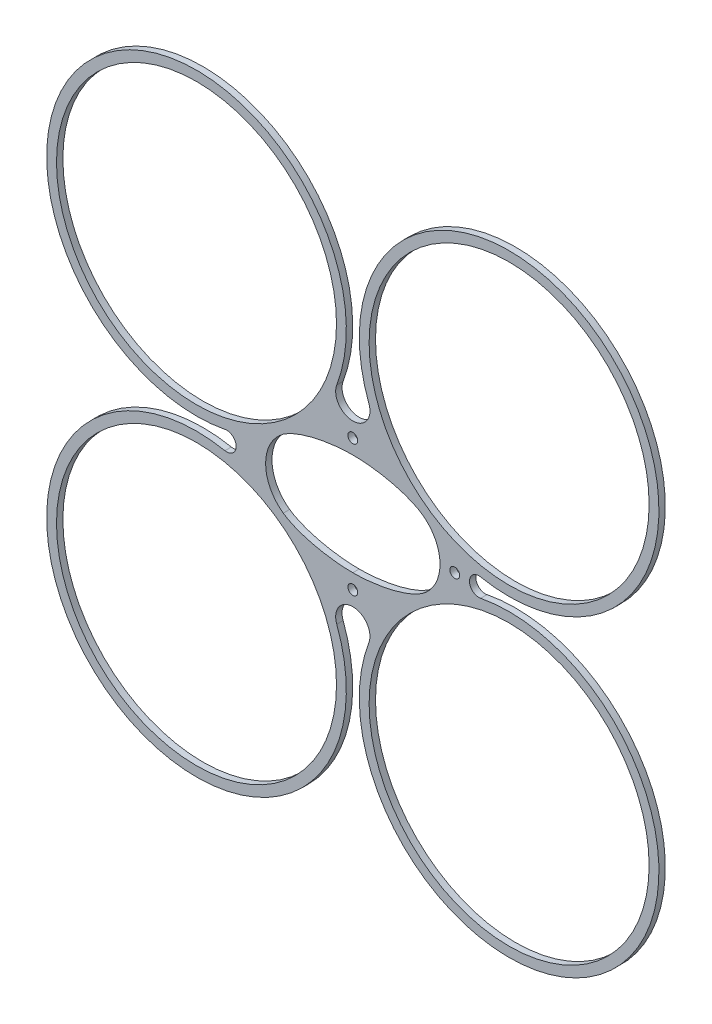
from build123d import *

# Parameters (mm, degrees)
SKETCH1_R             = 30.5
SKETCH1_R_2           = 28.5
BOSS_EXTRUDE1_DEPTH   = 1.3
BOSS_EXTRUDE1_2_DEPTH = 1.3
BOSS_EXTRUDE1_3_DEPTH = 1.3
BOSS_EXTRUDE1_4_DEPTH = 1.3
SKETCH3_R             = 1
BOSS_EXTRUDE2_DEPTH   = 1.3


with BuildPart() as part:
    # Sketch1 → Boss-Extrude1 (new body)
    with BuildSketch(Plane.XY):
        with Locations((-31.819805153, 31.819805153)):
            Circle(SKETCH1_R)
        with Locations((-31.819805153, 31.819805153)):
            Circle(SKETCH1_R_2, mode=Mode.SUBTRACT)
    extrude(amount=BOSS_EXTRUDE1_DEPTH)



with BuildPart() as body_2:
    # Sketch1 → Boss-Extrude1 2 (new body)
    with BuildSketch(Plane.XY):
        with Locations((31.819805153, 31.819805153)):
            Circle(SKETCH1_R)
        with Locations((31.819805153, 31.819805153)):
            Circle(SKETCH1_R_2, mode=Mode.SUBTRACT)
    extrude(amount=BOSS_EXTRUDE1_2_DEPTH)


with BuildPart() as body_3:
    # Sketch1 → Boss-Extrude1 3 (new body)
    with BuildSketch(Plane.XY):
        with Locations((31.819805153, -31.819805153)):
            Circle(SKETCH1_R)
        with Locations((31.819805153, -31.819805153)):
            Circle(SKETCH1_R_2, mode=Mode.SUBTRACT)
    extrude(amount=BOSS_EXTRUDE1_3_DEPTH)


with BuildPart() as body_4:
    # Sketch1 → Boss-Extrude1 4 (new body)
    with BuildSketch(Plane.XY):
        with Locations((-31.819805153, -31.819805153)):
            Circle(SKETCH1_R)
        with Locations((-31.819805153, -31.819805153)):
            Circle(SKETCH1_R_2, mode=Mode.SUBTRACT)
    extrude(amount=BOSS_EXTRUDE1_4_DEPTH)


with BuildPart() as part_1:
    add(part.part)

    add(body_2.part)  # Boss-Extrude2 merges body 2

    add(body_3.part)  # Boss-Extrude2 merges body 3

    add(body_4.part)  # Boss-Extrude2 merges body 4
    # Sketch3 → Boss-Extrude2 (add)
    with BuildSketch(Plane(origin=(0, 0, 0), x_dir=(-1, 0, 0), z_dir=(0, 0, -1))):
        with BuildLine():
            ThreePointArc((-23.75, 0), (-20.75, -3), (-17.75, 0))
            ThreePointArc((-17.75, 0), (-20.75, 3), (-23.75, 0))
        make_face()
        with Locations((-20.75, 0)):
            Circle(SKETCH3_R, mode=Mode.SUBTRACT)
        with BuildLine():
            ThreePointArc((-14.160081763, -6.952473777), (-16.799552066, -3.912301259), (-17.75, 0))
            ThreePointArc((-17.75, 0), (-20.75, -3), (-23.75, 0))
            ThreePointArc((-23.75, 0), (-24.444680466, -1.473679275), (-26.023521849, -1.875638779))
            ThreePointArc((-26.023521849, -1.875638779), (-19.820237414, -3.779470382), (-14.160081763, -6.952473777))
        make_face()
        with BuildLine():
            ThreePointArc((-23.75, 0), (-20.75, 3), (-17.75, 0))
            ThreePointArc((-17.75, 0), (-16.799552066, 3.912301259), (-14.160081763, 6.952473777))
            ThreePointArc((-14.160081763, 6.952473777), (-19.820237414, 3.779470382), (-26.023521849, 1.875638779))
            ThreePointArc((-26.023521849, 1.875638779), (-24.444680466, 1.473679275), (-23.75, 0))
        make_face()
        with BuildLine():
            add(Edge.make_bspline(
                [(-14.160081763, -6.952473777), (-14.006442935, -7.061581552), (-11.281305453, -8.851296282), (-5.533016891, -10.311083757), (-0.273902085, -10.375), (0, -10.375)],
                knots=[0, 0, 0, 0, 0.05, 0.95, 1, 1, 1, 1], degree=3))
            ThreePointArc((-14.160081763, -6.952473777), (-7.656423025, -13.208492354), (-3.268059498, -21.093770469))
            ThreePointArc((-3.268059498, -21.093770469), (-2.8699742, -17.878412259), (0, -16.375))
            ThreePointArc((0, -16.375), (-3, -13.375), (0, -10.375))
        make_face()
        with BuildLine():
            ThreePointArc((-3.268059498, 21.093770469), (-7.656423025, 13.208492354), (-14.160081763, 6.952473777))
            add(Edge.make_bspline(
                [(-14.160081763, 6.952473777), (-14.006442935, 7.061581552), (-11.281305453, 8.851296282), (-5.533016891, 10.311083757), (-0.273902085, 10.375), (0, 10.375)],
                knots=[0, 0, 0, 0, 0.05, 0.95, 1, 1, 1, 1], degree=3))
            ThreePointArc((0, 10.375), (-3, 13.375), (0, 16.375))
            ThreePointArc((0, 16.375), (-2.8699742, 17.878412259), (-3.268059498, 21.093770469))
        make_face()
        with BuildLine():
            add(Edge.make_bspline(
                [(14.160081763, -6.952473777), (14.006442935, -7.061581552), (11.281305453, -8.851296282), (5.533016891, -10.311083757), (0.273902085, -10.375), (0, -10.375)],
                knots=[0, 0, 0, 0, 0.05, 0.95, 1, 1, 1, 1], degree=3))
            ThreePointArc((0, -10.375), (2.121320344, -11.253679656), (3, -13.375))
            ThreePointArc((3, -13.375), (2.121320344, -15.496320344), (0, -16.375))
            ThreePointArc((0, -16.375), (2.8699742, -17.878412259), (3.268059498, -21.093770469))
            ThreePointArc((3.268059498, -21.093770469), (7.656423025, -13.208492354), (14.160081763, -6.952473777))
        make_face()
        with BuildLine():
            ThreePointArc((3, -13.375), (2.121320344, -11.253679656), (0, -10.375))
            ThreePointArc((0, -10.375), (-3, -13.375), (0, -16.375))
            ThreePointArc((0, -16.375), (2.121320344, -15.496320344), (3, -13.375))
        make_face()
        with Locations((0, -13.375)):
            Circle(SKETCH3_R, mode=Mode.SUBTRACT)
        with BuildLine():
            ThreePointArc((0, 16.375), (-3, 13.375), (0, 10.375))
            ThreePointArc((0, 10.375), (2.121320344, 11.253679656), (3, 13.375))
            ThreePointArc((3, 13.375), (2.121320344, 15.496320344), (0, 16.375))
        make_face()
        with Locations((0, 13.375)):
            Circle(SKETCH3_R, mode=Mode.SUBTRACT)
        with BuildLine():
            ThreePointArc((3, 13.375), (2.121320344, 11.253679656), (0, 10.375))
            add(Edge.make_bspline(
                [(14.160081763, 6.952473777), (14.006442935, 7.061581552), (11.281305453, 8.851296282), (5.533016891, 10.311083757), (0.273902085, 10.375), (0, 10.375)],
                knots=[0, 0, 0, 0, 0.05, 0.95, 1, 1, 1, 1], degree=3))
            ThreePointArc((14.160081763, 6.952473777), (7.656423025, 13.208492354), (3.268059498, 21.093770469))
            ThreePointArc((3.268059498, 21.093770469), (2.8699742, 17.878412259), (0, 16.375))
            ThreePointArc((0, 16.375), (2.121320344, 15.496320344), (3, 13.375))
        make_face()
        with BuildLine():
            ThreePointArc((17.75, 0), (16.799552066, -3.912301259), (14.160081763, -6.952473777))
            ThreePointArc((14.160081763, -6.952473777), (19.820237414, -3.779470382), (26.023521849, -1.875638779))
            ThreePointArc((26.023521849, -1.875638779), (24.444680466, -1.473679275), (23.75, 0))
            ThreePointArc((23.75, 0), (24.444680466, 1.473679275), (26.023521849, 1.875638779))
            ThreePointArc((26.023521849, 1.875638779), (19.820237414, 3.779470382), (14.160081763, 6.952473777))
            ThreePointArc((14.160081763, 6.952473777), (16.799552066, 3.912301259), (17.75, 0))
        make_face()
        with Locations((20.75, 0)):
            Circle(SKETCH3_R, mode=Mode.SUBTRACT)
        with Locations((20.75, 0)):
            Circle(SKETCH3_R)
    extrude(amount=-BOSS_EXTRUDE2_DEPTH)


solid = part_1.part
